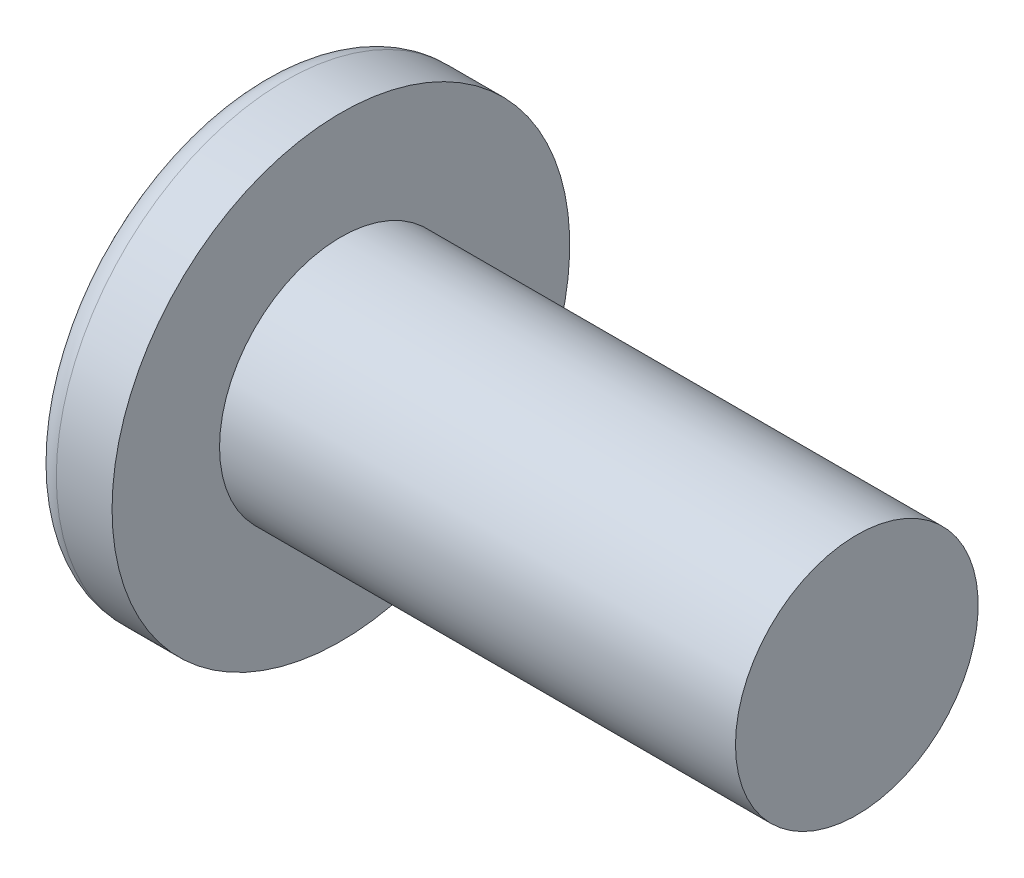
from build123d import *

# Parameters (mm, degrees)
SKETCH3_W         = 0.74
SKETCH3_H         = 2.9
SKETCH4_W         = 0.37
SKETCH4_H         = 0.37
CIRPATTERN1_COUNT = 2
CIRPATTERN1_ANGLE = 90


with BuildPart() as part:
    # BodySke → Base-Revolve (revolve)
    with BuildSketch(Plane.XY):
        with BuildLine():
            Line((1.9, 1.75), (1.9, 3.3))
            Line((1.9, 3.3), (1.096001453, 3.3))
            ThreePointArc((1.096001453, 3.3), (0.910881949, 3.248756812), (0.778463076, 3.109615385))
            ThreePointArc((0.778463076, 3.109615385), (0.197572972, 1.602787619), (0, 0))
            Line((0, 0), (9.34, 0))
            Line((9.34, 0), (9.34, 1.75))
            Line((9.34, 1.75), (1.9, 1.75))
        make_face()
    revolve(axis=Axis((-25.4, 0, 0), (1, 0, 0)))

    # Sketch3 → Cut-Loft1 section 0
    with BuildSketch(Plane(origin=(0, 0, 0), x_dir=(0, 0, -1), z_dir=(1, 0, 0))):
        Rectangle(SKETCH3_W, SKETCH3_H)
    # Sketch4 → Cut-Loft1 section 1
    with BuildSketch(Plane(origin=(1.76, 0, 0), x_dir=(0, 0, -1), z_dir=(1, 0, 0))):
        Rectangle(SKETCH4_W, SKETCH4_H)
    cut_loft1 = loft(mode=Mode.SUBTRACT)

    # CirPattern1: Cut-Loft1 ×2 about axis
    cirpattern1_axis = Axis((0, 0, 0), (1, 0, 0))
    for i in range(1, CIRPATTERN1_COUNT):
        add(cut_loft1.rotate(cirpattern1_axis, i * CIRPATTERN1_ANGLE / (CIRPATTERN1_COUNT - 1)), mode=Mode.SUBTRACT)


solid = part.part
